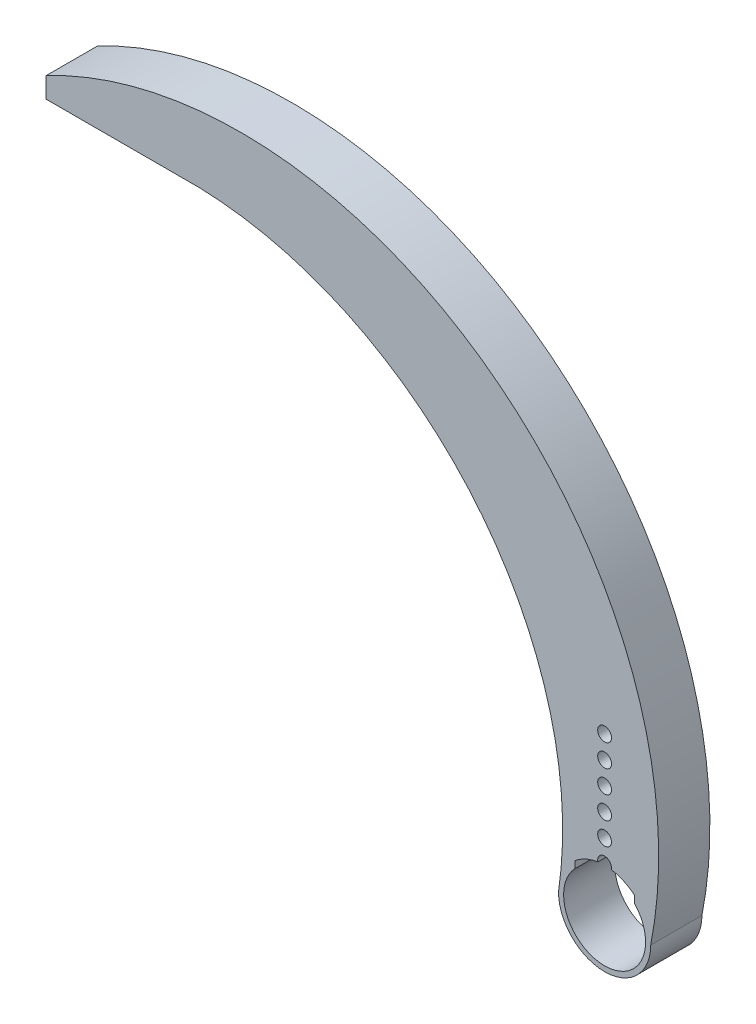
from build123d import *

# Parameters (mm, degrees)
BOSS_EXTRUDE1_DEPTH = 5
BOSS_EXTRUDE2_START = 5
SKETCH1_3_R         = 0.675
BOSS_EXTRUDE2_DEPTH = 2.5


with BuildPart() as part:
    # Sketch1 → Boss-Extrude1 (new body)
    with BuildSketch(Plane.XY):
        with BuildLine():
            ThreePointArc((4.5, 0), (-11.118671164, 40.613600031), (-54.5, 44))
            Line((-54.5, 44), (-54.5, 42))
            Line((-54.5, 42), (-39.5, 42))
            ThreePointArc((-39.5, 42), (-12.570901459, 28.857582118), (-4.5, 0))
            ThreePointArc((-4.5, 0), (0, -4.5), (4.5, 0))
        make_face()
        with BuildLine():
            Line((-2.900000039, 3.608329712), (-2.399984199, 15.608708951))
            ThreePointArc((-2.399984199, 15.608708951), (1e-09, 18), (2.399984199, 15.608708949))
            Line((2.399984199, 15.608708949), (2.899999961, 3.608329727))
            Line((2.899999961, 3.608329727), (2.899999994, 2.754995469))
            ThreePointArc((2.899999994, 2.754995469), (9e-09, -4), (-2.900000006, 2.754995456))
            Line((-2.900000006, 2.754995456), (-2.900000039, 3.608329712))
        make_face(mode=Mode.SUBTRACT)
    extrude(amount=BOSS_EXTRUDE1_DEPTH)

    # Sketch1_3 → Boss-Extrude2 (add)
    with BuildSketch(Plane.XY.offset(BOSS_EXTRUDE2_START)):
        with BuildLine():
            Line((2.899999967, 3.440930135), (2.899999961, 3.608329727))
            Line((2.899999961, 3.608329727), (2.399984199, 15.608708949))
            ThreePointArc((2.399984199, 15.608708949), (1e-09, 18), (-2.399984199, 15.608708951))
            Line((-2.399984199, 15.608708951), (-2.900000039, 3.608329712))
            Line((-2.900000039, 3.608329712), (-2.900000033, 3.440930079))
            ThreePointArc((-2.900000033, 3.440930079), (-1.84960355, 4.102312361), (-0.658476506, 4.4515625))
            ThreePointArc((-0.658476506, 4.4515625), (0, 5.275), (0.658476506, 4.4515625))
            ThreePointArc((0.658476506, 4.4515625), (1.849603511, 4.102312379), (2.899999967, 3.440930135))
        make_face()
        with Locations((0, 11.2)):
            Circle(SKETCH1_3_R, mode=Mode.SUBTRACT)
        with Locations((0, 13.4)):
            Circle(SKETCH1_3_R, mode=Mode.SUBTRACT)
        with Locations((0, 15.6)):
            Circle(SKETCH1_3_R, mode=Mode.SUBTRACT)
        with Locations((0, 6.8)):
            Circle(SKETCH1_3_R, mode=Mode.SUBTRACT)
        with Locations((0, 9)):
            Circle(SKETCH1_3_R, mode=Mode.SUBTRACT)
    extrude(amount=-BOSS_EXTRUDE2_DEPTH)


solid = part.part
